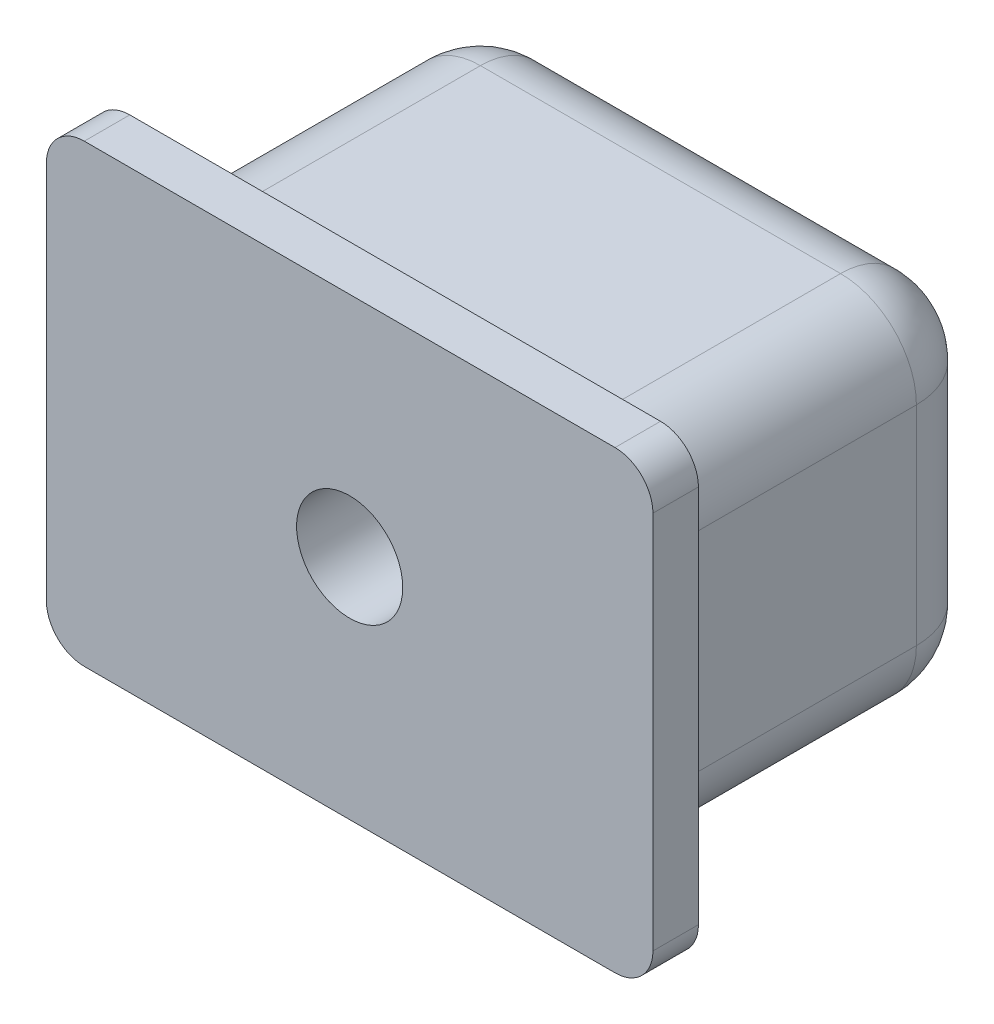
from build123d import *

# Parameters (mm, degrees)
SKETCH1_W           = 13.5
SKETCH1_H           = 9.5
BOSS_EXTRUDE1_DEPTH = 9
SKETCH2_W           = 16
SKETCH2_H           = 12
BOSS_EXTRUDE2_DEPTH = 1.2
SKETCH3_R           = 1.4
CUT_EXTRUDE1_DEPTH  = 5
FILLET1_R           = 2
FILLET2_R           = 2
FILLET3_R           = 0.4
FILLET4_R           = 1


with BuildPart() as part:
    # Sketch1 → Boss-Extrude1 (new body)
    with BuildSketch(Plane.XY):
        Rectangle(SKETCH1_W, SKETCH1_H)
    extrude(amount=BOSS_EXTRUDE1_DEPTH)

    # Sketch2 → Boss-Extrude2 (add)
    with BuildSketch(Plane.XY.offset(9)):
        Rectangle(SKETCH2_W, SKETCH2_H)
    extrude(amount=BOSS_EXTRUDE2_DEPTH)

    # Sketch3 → Cut-Extrude1 (cut)
    with BuildSketch(Plane.XY.offset(10.2)):
        Circle(SKETCH3_R)
    extrude(amount=-CUT_EXTRUDE1_DEPTH, mode=Mode.SUBTRACT)

    # Fillet1
    fillet1_edges = [part.edges().sort_by_distance(p)[0] for p in [
        (6.75, -4.75, 4.5),
        (-6.75, -4.75, 4.5),
        (-6.75, 4.75, 4.5),
        (6.75, 4.75, 4.5),
    ]]
    fillet(fillet1_edges, radius=FILLET1_R)

    # Fillet2
    fillet2_edges = [part.edges().sort_by_distance(p)[0] for p in [
        (0, -4.75, 0),
        (6.75, 0, 0),
        (-6.75, 0, 0),
        (0, 4.75, 0),
        (-6.164213562, 4.164213562, 0),
        (6.164213562, 4.164213562, 0),
        (6.164213562, -4.164213562, 0),
        (-6.164213562, -4.164213562, 0),
    ]]
    fillet(fillet2_edges, radius=FILLET2_R)

    # Fillet3
    fillet3_edges = [part.edges().sort_by_distance(p)[0] for p in [
        (0, -4.75, 9),
        (-6.75, 0, 9),
        (6.75, 0, 9),
        (0, 4.75, 9),
        (-6.164213562, -4.164213562, 9),
        (6.164213562, -4.164213562, 9),
        (6.164213562, 4.164213562, 9),
        (-6.164213562, 4.164213562, 9),
    ]]
    fillet(fillet3_edges, radius=FILLET3_R)

    # Fillet4
    fillet4_edges = [part.edges().sort_by_distance(p)[0] for p in [
        (8, -6, 9.6),
        (8, 6, 9.6),
        (-8, 6, 9.6),
        (-8, -6, 9.6),
    ]]
    fillet(fillet4_edges, radius=FILLET4_R)


solid = part.part
